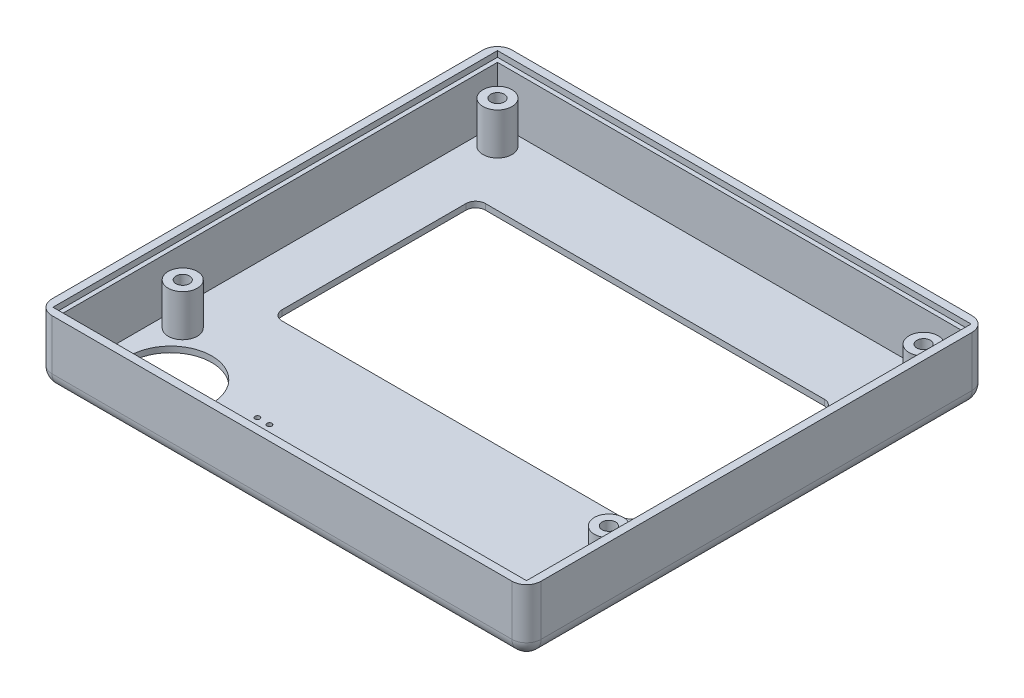
from build123d import *

# Parameters (mm, degrees)
SKETCH3_W           = 101
SKETCH3_H           = 95
BOSS_EXTRUDE2_DEPTH = 1.2
SKETCH5_W           = 101
SKETCH5_H           = 95
SKETCH5_W_2         = 96
SKETCH5_H_2         = 90
BOSS_EXTRUDE3_DEPTH = 11
SKETCH6_W           = 101
SKETCH6_H           = 95
SKETCH6_W_2         = 97.8
SKETCH6_H_2         = 91.8
BOSS_EXTRUDE4_DEPTH = 1.2
FILLET1_R           = 3
SKETCH7_R           = 3
BOSS_EXTRUDE5_DEPTH = 8.6
SKETCH8_R           = 1.4
CUT_EXTRUDE1_DEPTH  = 7
CUT_EXTRUDE2_REACH  = 3.2
SKETCH9_R           = 8.5
SKETCH9_R_2         = 0.5


with BuildPart() as part:
    # Sketch3 → Boss-Extrude2 (new body)
    with BuildSketch(Plane(origin=(0, 0, 0), x_dir=(1, 0, 0), z_dir=(0, 1, 0))):
        with Locations((46.5, 43.5)):
            Rectangle(SKETCH3_W, SKETCH3_H)
    extrude(amount=BOSS_EXTRUDE2_DEPTH)

    # Sketch5 → Boss-Extrude3 (add)
    with BuildSketch(Plane(origin=(0, 1.2, 0), x_dir=(1, 0, 0), z_dir=(0, 1, 0))):
        with Locations((46.5, 43.5)):
            Rectangle(SKETCH5_W, SKETCH5_H)
        with Locations((46.5, 43.5)):
            Rectangle(SKETCH5_W_2, SKETCH5_H_2, mode=Mode.SUBTRACT)
    extrude(amount=BOSS_EXTRUDE3_DEPTH)

    # Sketch6 → Boss-Extrude4 (add)
    with BuildSketch(Plane(origin=(0, 12.2, 0), x_dir=(1, 0, 0), z_dir=(0, 1, 0))):
        with Locations((46.5, 43.5)):
            Rectangle(SKETCH6_W, SKETCH6_H)
        with Locations((46.5, 43.5)):
            Rectangle(SKETCH6_W_2, SKETCH6_H_2, mode=Mode.SUBTRACT)
    extrude(amount=BOSS_EXTRUDE4_DEPTH)

    # Fillet1
    fillet1_edges = [part.edges().sort_by_distance(p)[0] for p in [
        (46.5, 0, -91),
        (97, 0, -43.5),
        (46.5, 0, 4),
        (-4, 0, -43.5),
        (-4, 6.7, -91),
        (97, 6.7, -91),
        (97, 6.7, 4),
        (-4, 6.7, 4),
    ]]
    fillet(fillet1_edges, radius=FILLET1_R)

    # Sketch7 → Boss-Extrude5 (add)
    with BuildSketch(Plane(origin=(0, 1.2, 0), x_dir=(1, 0, 0), z_dir=(0, 1, 0))):
        with Locations((2.5, 84.5)):
            Circle(SKETCH7_R)
        with Locations((90.5, 84.5)):
            Circle(SKETCH7_R)
        with Locations((90.5, 19.5)):
            Circle(SKETCH7_R)
        with Locations((2.5, 19.5)):
            Circle(SKETCH7_R)
    extrude(amount=BOSS_EXTRUDE5_DEPTH)

    # Sketch8 → Cut-Extrude1 (cut)
    with BuildSketch(Plane(origin=(0, 9.8, 0), x_dir=(1, 0, 0), z_dir=(0, 1, 0))):
        with Locations((2.5, 84.5)):
            Circle(SKETCH8_R)
        with Locations((90.5, 84.5)):
            Circle(SKETCH8_R)
        with Locations((90.5, 19.5)):
            Circle(SKETCH8_R)
        with Locations((2.5, 19.5)):
            Circle(SKETCH8_R)
    extrude(amount=-CUT_EXTRUDE1_DEPTH, mode=Mode.SUBTRACT)

    # Sketch9 → Cut-Extrude2 (cut, up to next)
    with BuildSketch(Plane(origin=(0, 1.2, 0), x_dir=(1, 0, 0), z_dir=(0, 1, 0)), mode=Mode.PRIVATE) as cut_extrude2_sk1:
        with Locations((10.5, 9)):
            Circle(SKETCH9_R)
    cut_extrude2_tool1 = extrude(cut_extrude2_sk1.sketch, amount=-CUT_EXTRUDE2_REACH, mode=Mode.PRIVATE) & part.part
    add(cut_extrude2_tool1.solids().sort_by_distance((10.5, 1.2, -9))[0], mode=Mode.SUBTRACT)
    # Sketch9 → Cut-Extrude2 (cut, up to next)
    with BuildSketch(Plane(origin=(0, 1.2, 0), x_dir=(1, 0, 0), z_dir=(0, 1, 0)), mode=Mode.PRIVATE) as cut_extrude2_sk2:
        with Locations((27.5, 9)):
            Circle(SKETCH9_R_2)
    cut_extrude2_tool2 = extrude(cut_extrude2_sk2.sketch, amount=-CUT_EXTRUDE2_REACH, mode=Mode.PRIVATE) & part.part
    add(cut_extrude2_tool2.solids().sort_by_distance((27.5, 1.2, -9))[0], mode=Mode.SUBTRACT)
    # Sketch9 → Cut-Extrude2 (cut, up to next)
    with BuildSketch(Plane(origin=(0, 1.2, 0), x_dir=(1, 0, 0), z_dir=(0, 1, 0)), mode=Mode.PRIVATE) as cut_extrude2_sk3:
        with Locations((28.75, 11.165063509)):
            Circle(SKETCH9_R_2)
    cut_extrude2_tool3 = extrude(cut_extrude2_sk3.sketch, amount=-CUT_EXTRUDE2_REACH, mode=Mode.PRIVATE) & part.part
    add(cut_extrude2_tool3.solids().sort_by_distance((28.75, 1.2, -11.165064))[0], mode=Mode.SUBTRACT)
    # Sketch9 → Cut-Extrude2 (cut, up to next)
    with BuildSketch(Plane(origin=(0, 1.2, 0), x_dir=(1, 0, 0), z_dir=(0, 1, 0)), mode=Mode.PRIVATE) as cut_extrude2_sk4:
        with Locations((26.25, 11.165063509)):
            Circle(SKETCH9_R_2)
    cut_extrude2_tool4 = extrude(cut_extrude2_sk4.sketch, amount=-CUT_EXTRUDE2_REACH, mode=Mode.PRIVATE) & part.part
    add(cut_extrude2_tool4.solids().sort_by_distance((26.25, 1.2, -11.165064))[0], mode=Mode.SUBTRACT)
    # Sketch9 → Cut-Extrude2 (cut, up to next)
    with BuildSketch(Plane(origin=(0, 1.2, 0), x_dir=(1, 0, 0), z_dir=(0, 1, 0)), mode=Mode.PRIVATE) as cut_extrude2_sk5:
        with Locations((25, 9)):
            Circle(SKETCH9_R_2)
    cut_extrude2_tool5 = extrude(cut_extrude2_sk5.sketch, amount=-CUT_EXTRUDE2_REACH, mode=Mode.PRIVATE) & part.part
    add(cut_extrude2_tool5.solids().sort_by_distance((25, 1.2, -9))[0], mode=Mode.SUBTRACT)
    # Sketch9 → Cut-Extrude2 (cut, up to next)
    with BuildSketch(Plane(origin=(0, 1.2, 0), x_dir=(1, 0, 0), z_dir=(0, 1, 0)), mode=Mode.PRIVATE) as cut_extrude2_sk6:
        with Locations((26.25, 6.834936491)):
            Circle(SKETCH9_R_2)
    cut_extrude2_tool6 = extrude(cut_extrude2_sk6.sketch, amount=-CUT_EXTRUDE2_REACH, mode=Mode.PRIVATE) & part.part
    add(cut_extrude2_tool6.solids().sort_by_distance((26.25, 1.2, -6.834936))[0], mode=Mode.SUBTRACT)
    # Sketch9 → Cut-Extrude2 (cut, up to next)
    with BuildSketch(Plane(origin=(0, 1.2, 0), x_dir=(1, 0, 0), z_dir=(0, 1, 0)), mode=Mode.PRIVATE) as cut_extrude2_sk7:
        with Locations((28.75, 6.834936491)):
            Circle(SKETCH9_R_2)
    cut_extrude2_tool7 = extrude(cut_extrude2_sk7.sketch, amount=-CUT_EXTRUDE2_REACH, mode=Mode.PRIVATE) & part.part
    add(cut_extrude2_tool7.solids().sort_by_distance((28.75, 1.2, -6.834936))[0], mode=Mode.SUBTRACT)
    # Sketch9 → Cut-Extrude2 (cut, up to next)
    with BuildSketch(Plane(origin=(0, 1.2, 0), x_dir=(1, 0, 0), z_dir=(0, 1, 0)), mode=Mode.PRIVATE) as cut_extrude2_sk8:
        with Locations((30, 9)):
            Circle(SKETCH9_R_2)
    cut_extrude2_tool8 = extrude(cut_extrude2_sk8.sketch, amount=-CUT_EXTRUDE2_REACH, mode=Mode.PRIVATE) & part.part
    add(cut_extrude2_tool8.solids().sort_by_distance((30, 1.2, -9))[0], mode=Mode.SUBTRACT)
    # Sketch9 → Cut-Extrude2 (cut, up to next)
    with BuildSketch(Plane(origin=(0, 1.2, 0), x_dir=(1, 0, 0), z_dir=(0, 1, 0)), mode=Mode.PRIVATE) as cut_extrude2_sk9:
        with BuildLine():
            Line((11.5, 31), (81.5, 31))
            ThreePointArc((81.5, 31), (82.914213562, 31.585786438), (83.5, 33))
            Line((83.5, 33), (83.5, 71))
            ThreePointArc((83.5, 71), (82.914213562, 72.414213562), (81.5, 73))
            Line((81.5, 73), (11.5, 73))
            ThreePointArc((11.5, 73), (10.085786438, 72.414213562), (9.5, 71))
            Line((9.5, 71), (9.5, 33))
            ThreePointArc((9.5, 33), (10.085786438, 31.585786438), (11.5, 31))
        make_face()
    cut_extrude2_tool9 = extrude(cut_extrude2_sk9.sketch, amount=-CUT_EXTRUDE2_REACH, mode=Mode.PRIVATE) & part.part
    add(cut_extrude2_tool9.solids().sort_by_distance((46.5, 1.2, -52))[0], mode=Mode.SUBTRACT)


solid = part.part
